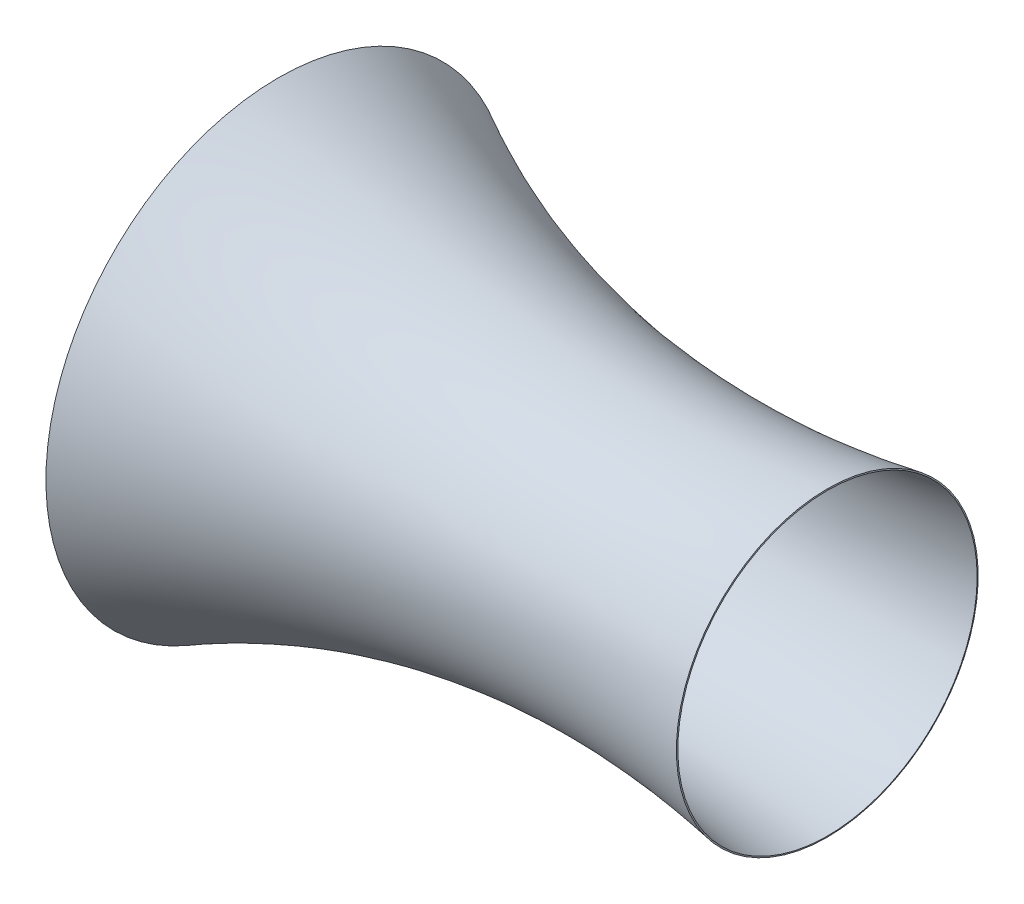
from build123d import *

# Parameters (mm, degrees)
THICKEN1_T1 = 5


with BuildPart() as body_1:
    # Surface-Revolve1: a surface, the sketch's curves turned about an axis
    with BuildLine(Plane.XY, mode=Mode.PRIVATE) as surface_revolve1_1_path:
        Line((58.164522356, 830), (33.164522356, 830))
        Line((33.164522356, 830), (25, 800))
        Line((25, 800), (0, 800))
        add(Edge.make_bspline(
            [(0, 800), (-40.64487716, 858.757553751), (0, 924.826053007)],
            knots=[0, 0, 0, 1, 1, 1], degree=2))
        add(Edge.make_bspline(
            [(0, 924.826053007), (1006.750903872, 389.756171393), (2200, 600)],
            knots=[0, 0, 0, 1, 1, 1], degree=2))
    surface_revolve1_1 = Shell.revolve(surface_revolve1_1_path.wire(), 360, Axis((0, 0, 0), (1, 0, 0)))
    add(Solid.thicken(surface_revolve1_1, THICKEN1_T1))


solid = body_1.part
